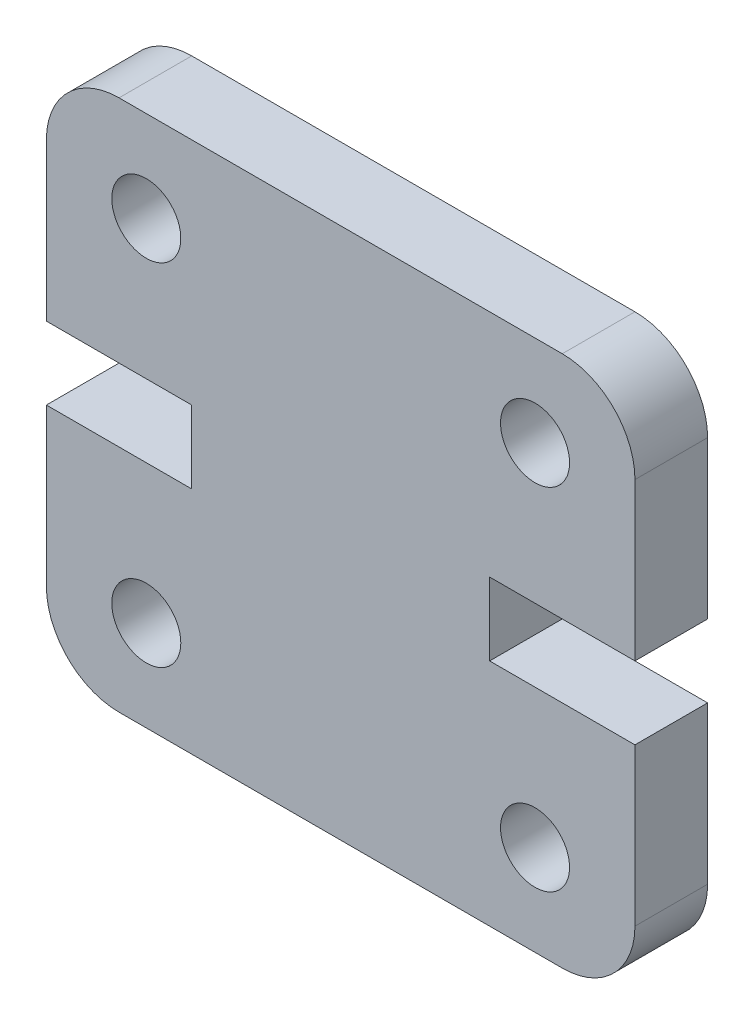
from build123d import *

# Parameters (mm, degrees)
SKETCH1_R           = 0.95
BOSS_EXTRUDE1_DEPTH = 4
SKETCH2_W           = 16.2
SKETCH2_H           = 14.645
CUT_EXTRUDE1_DEPTH  = 2


with BuildPart() as part:
    # Sketch1 → Boss-Extrude1 (new body)
    with BuildSketch(Plane.XY):
        with BuildLine():
            Line((2, 14.645), (14.2, 14.645))
            ThreePointArc((14.2, 14.645), (15.614213562, 14.059213562), (16.2, 12.645))
            Line((16.2, 12.645), (16.2, 8.3225))
            Line((16.2, 8.3225), (12.2, 8.3225))
            Line((12.2, 8.3225), (12.2, 6.3225))
            Line((12.2, 6.3225), (16.2, 6.3225))
            Line((16.2, 6.3225), (16.2, 2))
            ThreePointArc((16.2, 2), (15.614213562, 0.585786438), (14.2, 0))
            Line((14.2, 0), (2, 0))
            ThreePointArc((2, 0), (0.585786438, 0.585786438), (0, 2))
            Line((0, 2), (0, 6.3225))
            Line((0, 6.3225), (4, 6.3225))
            Line((4, 6.3225), (4, 8.3225))
            Line((4, 8.3225), (0, 8.3225))
            Line((0, 8.3225), (0, 12.645))
            ThreePointArc((0, 12.645), (0.585786438, 14.059213562), (2, 14.645))
        make_face()
        with Locations((2.75, 12.145)):
            Circle(SKETCH1_R, mode=Mode.SUBTRACT)
        with Locations((13.45, 2.5)):
            Circle(SKETCH1_R, mode=Mode.SUBTRACT)
        with Locations((13.45, 12.145)):
            Circle(SKETCH1_R, mode=Mode.SUBTRACT)
        with Locations((2.75, 2.5)):
            Circle(SKETCH1_R, mode=Mode.SUBTRACT)
    extrude(amount=BOSS_EXTRUDE1_DEPTH)

    # Sketch2 → Cut-Extrude1 (cut)
    with BuildSketch(Plane(origin=(0, 0, 0), x_dir=(-1, 0, 0), z_dir=(0, 0, -1))):
        with Locations((-8.1, 7.3225)):
            Rectangle(SKETCH2_W, SKETCH2_H)
    extrude(amount=-CUT_EXTRUDE1_DEPTH, mode=Mode.SUBTRACT)


solid = part.part
